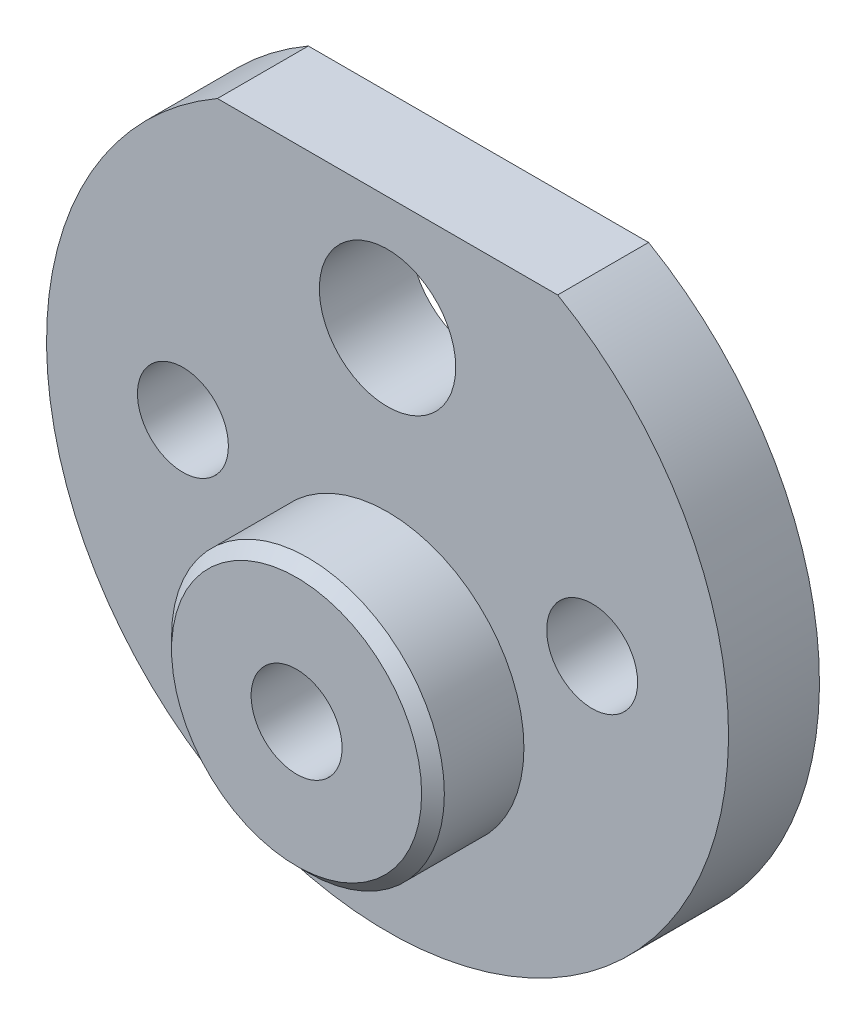
from build123d import *

# Parameters (mm, degrees)
SKETCH1_R           = 3
SKETCH1_R_2         = 2
BOSS_EXTRUDE1_DEPTH = 4
SKETCH2_R           = 6
BOSS_EXTRUDE2_DEPTH = 4
SKETCH3_R           = 2
CUT_EXTRUDE1_DEPTH  = 9
CHAMFER1_SIZE       = 0.5


with BuildPart() as part:
    # Sketch1 → Boss-Extrude1 (new body)
    with BuildSketch(Plane.XY):
        with BuildLine():
            Line((-7.483314774, 13), (7.483314774, 13))
            ThreePointArc((7.483314774, 13), (0, -15), (-7.483314774, 13))
        make_face()
        with Locations((0, 8)):
            Circle(SKETCH1_R, mode=Mode.SUBTRACT)
        with Locations((-9, 0)):
            Circle(SKETCH1_R_2, mode=Mode.SUBTRACT)
        with Locations((9, 0)):
            Circle(SKETCH1_R_2, mode=Mode.SUBTRACT)
    extrude(amount=BOSS_EXTRUDE1_DEPTH)

    # Sketch2 → Boss-Extrude2 (add)
    with BuildSketch(Plane.XY.offset(4)):
        with Locations((0, -5)):
            Circle(SKETCH2_R)
    extrude(amount=BOSS_EXTRUDE2_DEPTH)

    # Sketch3 → Cut-Extrude1 (cut, through all)
    with BuildSketch(Plane.XY.offset(8)):
        with Locations((0, -5)):
            Circle(SKETCH3_R)
    extrude(amount=-CUT_EXTRUDE1_DEPTH, mode=Mode.SUBTRACT)

    # Chamfer1
    chamfer1_edges = [part.edges().sort_by_distance(p)[0] for p in [
        (-6, -5, 8),
    ]]
    chamfer(chamfer1_edges, length=CHAMFER1_SIZE)


solid = part.part
